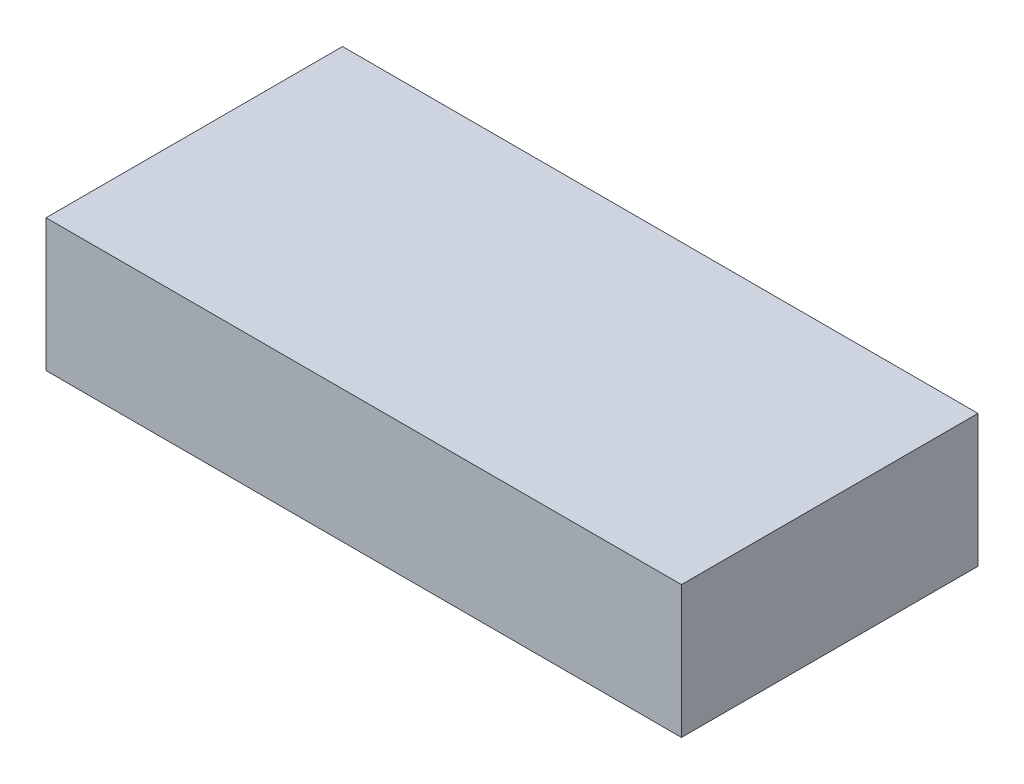
from build123d import *

# Parameters (mm, degrees)
SKETCH1_W           = 120
SKETCH1_H           = 56
BOSS_EXTRUDE1_DEPTH = 25


with BuildPart() as part:
    # Sketch1 → Boss-Extrude1 (new body)
    with BuildSketch(Plane(origin=(0, 0, 0), x_dir=(1, 0, 0), z_dir=(0, 1, 0))):
        with Locations((60, 28)):
            Rectangle(SKETCH1_W, SKETCH1_H)
    extrude(amount=BOSS_EXTRUDE1_DEPTH)


solid = part.part
